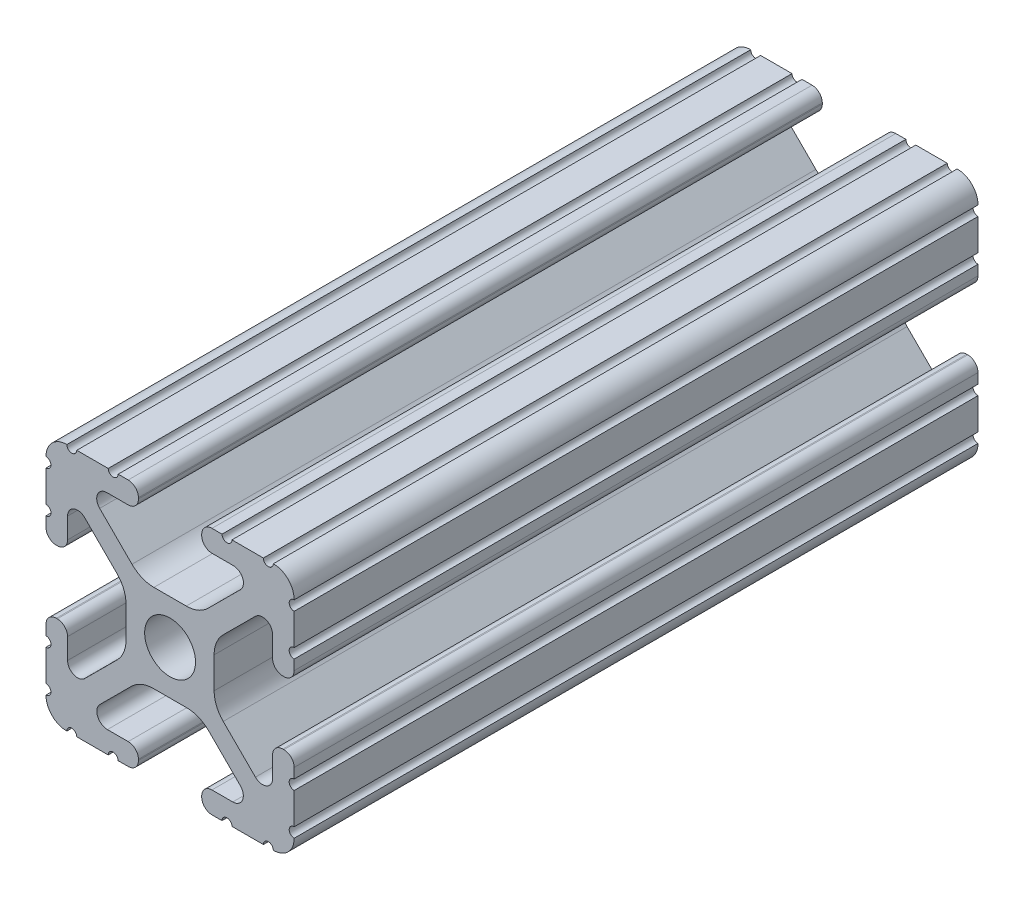
from build123d import *

# Parameters (mm, degrees)
SKETCH1_R           = 2.6035
BOSS_EXTRUDE1_DEPTH = 35


with BuildPart() as part:
    # Sketch1 → Boss-Extrude1 (new body, symmetric)
    with BuildSketch(Plane.XY):
        with BuildLine():
            Line((-7.179650497, -8.645192506), (-3.952270251, -5.423690499))
            ThreePointArc((-3.952270251, -5.423690499), (-2.922936451, -4.736929036), (-1.709253557, -4.4958))
            Line((-1.709253557, -4.4958), (1.709253557, -4.4958))
            ThreePointArc((1.709253557, -4.4958), (2.922936451, -4.736929036), (3.952270251, -5.423690499))
            Line((3.952270251, -5.423690499), (7.179650497, -8.645192506))
            ThreePointArc((7.179650497, -8.645192506), (7.41473083, -9.822813117), (6.416408329, -10.4902))
            Line((6.416408329, -10.4902), (4.287512407, -10.4902))
            ThreePointArc((4.287512407, -10.4902), (3.54574862, -10.79744862), (3.2385, -11.539212407))
            Line((3.2385, -11.539212407), (3.2385, -11.650987593))
            ThreePointArc((3.2385, -11.650987593), (3.54574862, -12.39275138), (4.287512407, -12.7))
            Line((4.287512407, -12.7), (5.317126718, -12.7))
            ThreePointArc((5.317126718, -12.7), (5.825126718, -12.192), (6.333126718, -12.7))
            Line((6.333126718, -12.7), (9.550443118, -12.7))
            ThreePointArc((9.550443118, -12.7), (10.058366869, -12.192000006), (10.566443095, -12.699847501))
            ThreePointArc((10.566443095, -12.699847501), (12.082537762, -12.08250727), (12.699846982, -10.566399977))
            ThreePointArc((12.699846982, -10.566399977), (12.192000006, -10.058323491), (12.7, -9.5504))
            Line((12.7, -9.5504), (12.7, -6.3330836))
            ThreePointArc((12.7, -6.3330836), (12.192, -5.8250836), (12.7, -5.3170836))
            Line((12.7, -5.3170836), (12.7, -4.287469289))
            ThreePointArc((12.7, -4.287469289), (12.39275138, -3.545705502), (11.650987593, -3.238456882))
            Line((11.650987593, -3.238456882), (11.539212407, -3.238456882))
            ThreePointArc((11.539212407, -3.238456882), (10.79744862, -3.545705502), (10.4902, -4.287469289))
            Line((10.4902, -4.287469289), (10.4902, -6.402089023))
            ThreePointArc((10.4902, -6.402089023), (9.856505071, -7.351067942), (8.737131347, -7.129408934))
            Line((8.737131347, -7.129408934), (5.441005833, -3.840816462))
            ThreePointArc((5.441005833, -3.840816462), (4.750877967, -2.809883091), (4.5085, -1.593185507))
            Line((4.5085, -1.593185507), (4.5085, 1.593185507))
            ThreePointArc((4.5085, 1.593185507), (4.750877967, 2.809883091), (5.441005833, 3.840816462))
            Line((5.441005833, 3.840816462), (8.737131347, 7.129408934))
            ThreePointArc((8.737131347, 7.129408934), (9.856505071, 7.351067942), (10.4902, 6.402089023))
            Line((10.4902, 6.402089023), (10.4902, 4.287469289))
            ThreePointArc((10.4902, 4.287469289), (10.79744862, 3.545705502), (11.539212407, 3.238456882))
            Line((11.539212407, 3.238456882), (11.650987593, 3.238456882))
            ThreePointArc((11.650987593, 3.238456882), (12.39275138, 3.545705502), (12.7, 4.287469289))
            Line((12.7, 4.287469289), (12.7, 5.3170836))
            ThreePointArc((12.7, 5.3170836), (12.192, 5.8250836), (12.7, 6.3330836))
            Line((12.7, 6.3330836), (12.7, 9.5504))
            ThreePointArc((12.7, 9.5504), (12.192000006, 10.058323491), (12.699846982, 10.566399977))
            ThreePointArc((12.699846982, 10.566399977), (12.082537762, 12.08250727), (10.566443095, 12.699847501))
            ThreePointArc((10.566443095, 12.699847501), (10.058366869, 12.192000006), (9.550443118, 12.7))
            Line((9.550443118, 12.7), (6.333126718, 12.7))
            ThreePointArc((6.333126718, 12.7), (5.825126718, 12.192), (5.317126718, 12.7))
            Line((5.317126718, 12.7), (4.287512407, 12.7))
            ThreePointArc((4.287512407, 12.7), (3.54574862, 12.39275138), (3.2385, 11.650987593))
            Line((3.2385, 11.650987593), (3.2385, 11.539212407))
            ThreePointArc((3.2385, 11.539212407), (3.54574862, 10.79744862), (4.287512407, 10.4902))
            Line((4.287512407, 10.4902), (6.476788598, 10.4902))
            ThreePointArc((6.476788598, 10.4902), (7.432222385, 9.85140422), (7.207036008, 8.724370562))
            Line((7.207036008, 8.724370562), (3.898272566, 5.423169045))
            ThreePointArc((3.898272566, 5.423169045), (2.869120213, 4.736787962), (1.655778399, 4.4958))
            Line((1.655778399, 4.4958), (-1.655778399, 4.4958))
            ThreePointArc((-1.655778399, 4.4958), (-2.869120213, 4.736787962), (-3.898272566, 5.423169045))
            Line((-3.898272566, 5.423169045), (-7.207036008, 8.724370562))
            ThreePointArc((-7.207036008, 8.724370562), (-7.432222385, 9.85140422), (-6.476788598, 10.4902))
            Line((-6.476788598, 10.4902), (-4.287512407, 10.4902))
            ThreePointArc((-4.287512407, 10.4902), (-3.54574862, 10.79744862), (-3.2385, 11.539212407))
            Line((-3.2385, 11.539212407), (-3.2385, 11.650987593))
            ThreePointArc((-3.2385, 11.650987593), (-3.54574862, 12.39275138), (-4.287512407, 12.7))
            Line((-4.287512407, 12.7), (-5.317126718, 12.7))
            ThreePointArc((-5.317126718, 12.7), (-5.825126718, 12.192), (-6.333126718, 12.7))
            Line((-6.333126718, 12.7), (-9.550443118, 12.7))
            ThreePointArc((-9.550443118, 12.7), (-10.058366869, 12.192000006), (-10.566443095, 12.699847501))
            ThreePointArc((-10.566443095, 12.699847501), (-12.082537762, 12.08250727), (-12.699846982, 10.566399977))
            ThreePointArc((-12.699846982, 10.566399977), (-12.192000006, 10.058323491), (-12.7, 9.5504))
            Line((-12.7, 9.5504), (-12.7, 6.3330836))
            ThreePointArc((-12.7, 6.3330836), (-12.192, 5.8250836), (-12.7, 5.3170836))
            Line((-12.7, 5.3170836), (-12.7, 4.287469289))
            ThreePointArc((-12.7, 4.287469289), (-12.39275138, 3.545705502), (-11.650987593, 3.238456882))
            Line((-11.650987593, 3.238456882), (-11.539212407, 3.238456882))
            ThreePointArc((-11.539212407, 3.238456882), (-10.79744862, 3.545705502), (-10.4902, 4.287469289))
            Line((-10.4902, 4.287469289), (-10.4902, 6.402089023))
            ThreePointArc((-10.4902, 6.402089023), (-9.856505071, 7.351067942), (-8.737131347, 7.129408934))
            Line((-8.737131347, 7.129408934), (-5.441005833, 3.840816462))
            ThreePointArc((-5.441005833, 3.840816462), (-4.750877967, 2.809883091), (-4.5085, 1.593185507))
            Line((-4.5085, 1.593185507), (-4.5085, -1.593185507))
            ThreePointArc((-4.5085, -1.593185507), (-4.750877967, -2.809883091), (-5.441005833, -3.840816462))
            Line((-5.441005833, -3.840816462), (-8.737131347, -7.129408934))
            ThreePointArc((-8.737131347, -7.129408934), (-9.856505071, -7.351067942), (-10.4902, -6.402089023))
            Line((-10.4902, -6.402089023), (-10.4902, -4.287469289))
            ThreePointArc((-10.4902, -4.287469289), (-10.79744862, -3.545705502), (-11.539212407, -3.238456882))
            Line((-11.539212407, -3.238456882), (-11.650987593, -3.238456882))
            ThreePointArc((-11.650987593, -3.238456882), (-12.39275138, -3.545705502), (-12.7, -4.287469289))
            Line((-12.7, -4.287469289), (-12.7, -5.3170836))
            ThreePointArc((-12.7, -5.3170836), (-12.192, -5.8250836), (-12.7, -6.3330836))
            Line((-12.7, -6.3330836), (-12.7, -9.5504))
            ThreePointArc((-12.7, -9.5504), (-12.192000006, -10.058323491), (-12.699846982, -10.566399977))
            ThreePointArc((-12.699846982, -10.566399977), (-12.082537762, -12.08250727), (-10.566443095, -12.699847501))
            ThreePointArc((-10.566443095, -12.699847501), (-10.058366869, -12.192000006), (-9.550443118, -12.7))
            Line((-9.550443118, -12.7), (-6.333126718, -12.7))
            ThreePointArc((-6.333126718, -12.7), (-5.825126718, -12.192), (-5.317126718, -12.7))
            Line((-5.317126718, -12.7), (-4.287512407, -12.7))
            ThreePointArc((-4.287512407, -12.7), (-3.54574862, -12.39275138), (-3.2385, -11.650987593))
            Line((-3.2385, -11.650987593), (-3.2385, -11.539212407))
            ThreePointArc((-3.2385, -11.539212407), (-3.54574862, -10.79744862), (-4.287512407, -10.4902))
            Line((-4.287512407, -10.4902), (-6.416408329, -10.4902))
            ThreePointArc((-6.416408329, -10.4902), (-7.41473083, -9.822813117), (-7.179650497, -8.645192506))
        make_face()
        Circle(SKETCH1_R, mode=Mode.SUBTRACT)
    extrude(amount=BOSS_EXTRUDE1_DEPTH, both=True)


solid = part.part
